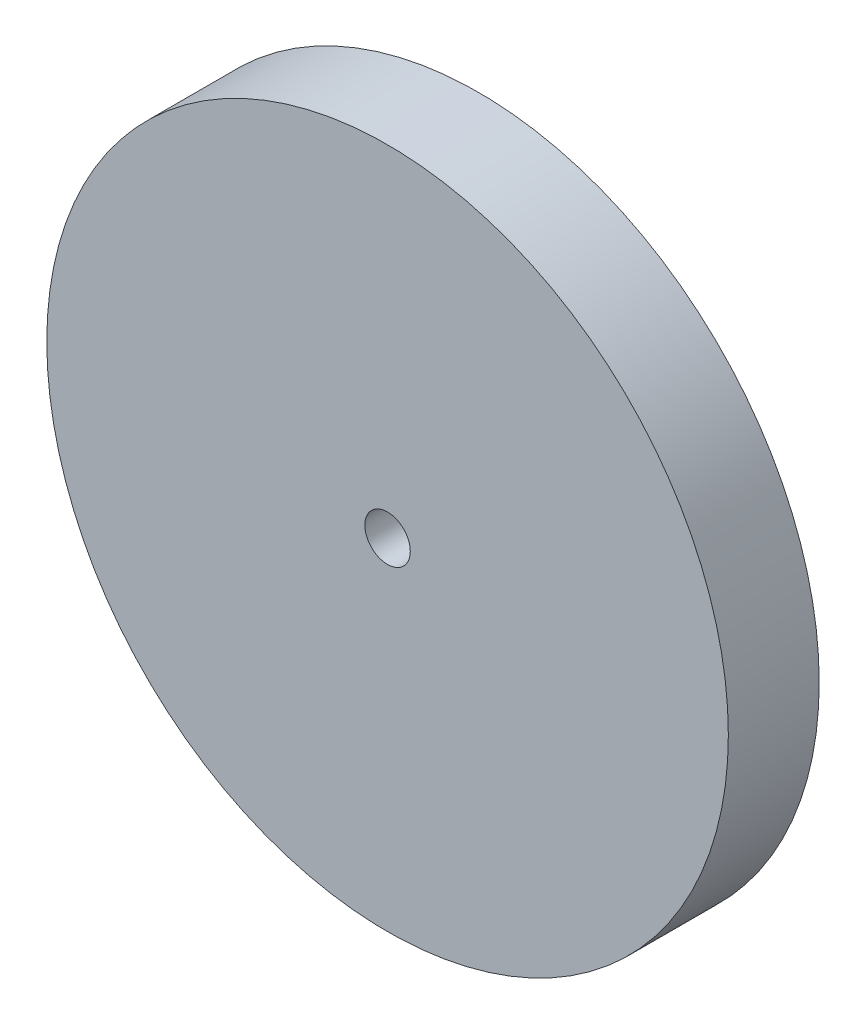
from build123d import *

# Parameters (mm, degrees)
SKETCH_1_R          = 15
EXTRUDE_1_DEPTH     = 4
SKETCH_2_R          = 1
CUT_EXTRUDE_1_DEPTH = 5


with BuildPart() as part:
    # 草图1 → 凸台-拉伸1 (new body)
    with BuildSketch(Plane.XY):
        Circle(SKETCH_1_R)
    extrude(amount=EXTRUDE_1_DEPTH)

    # 草图2 → 切除-拉伸1 (cut, through all)
    with BuildSketch(Plane.XY.offset(4)):
        Circle(SKETCH_2_R)
    extrude(amount=-CUT_EXTRUDE_1_DEPTH, mode=Mode.SUBTRACT)


solid = part.part
